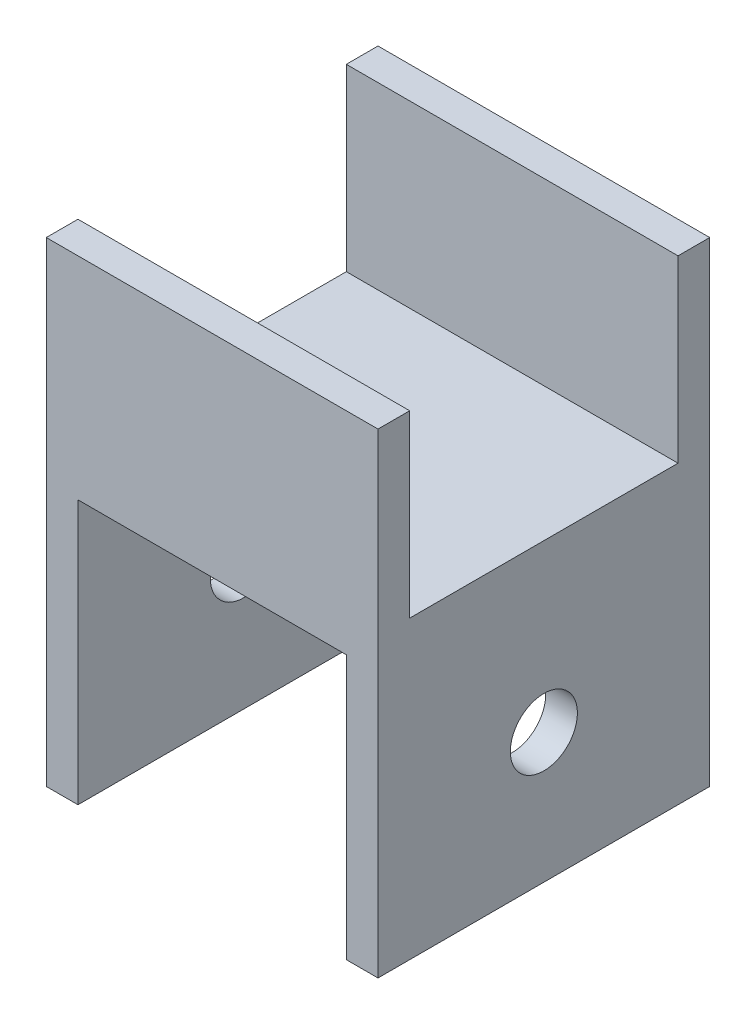
from build123d import *

# Parameters (mm, degrees)
BOSS_EXTRUDE1_DEPTH         = 31.4
SKETCH2_W                   = 3
SKETCH2_H                   = 31.4
BOSS_EXTRUDE2_DEPTH         = 25
F_1_4_0_25_DIAMETER_HOLE1_D = 6.35


with BuildPart() as part:
    # Sketch1 → Boss-Extrude1 (new body)
    with BuildSketch(Plane(origin=(0, 0, 0), x_dir=(0, 0, -1), z_dir=(1, 0, 0))):
        Polygon((0, 0), (0, 20), (3, 20), (3, 3), (28.4, 3), (28.4, 20), (31.4, 20), (31.4, 0), align=None)
    extrude(amount=BOSS_EXTRUDE1_DEPTH)

    # Sketch2 → Boss-Extrude2 (add)
    with BuildSketch(Plane.XZ):
        with Locations((29.9, -15.7)):
            Rectangle(SKETCH2_W, SKETCH2_H)
        with Locations((1.5, -15.7)):
            Rectangle(SKETCH2_W, SKETCH2_H)
    extrude(amount=BOSS_EXTRUDE2_DEPTH)

    # 1/4 (0.25) Diameter Hole1 (through all)
    with Locations(Plane(origin=(31.4, 0, 0), x_dir=(0, 0, -1), z_dir=(1, 0, 0))):
        with Locations((15.7, -12.7)):
            Hole(F_1_4_0_25_DIAMETER_HOLE1_D / 2)


solid = part.part
